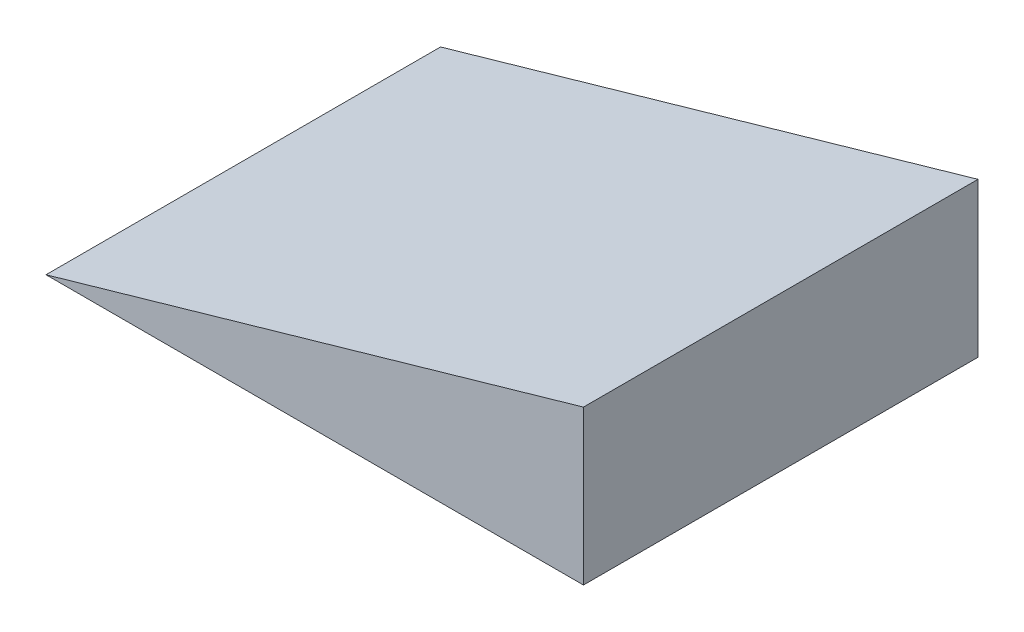
from build123d import *

# Parameters (mm, degrees)
BOSS_EXTRUDE1_DEPTH = 406.4


with BuildPart() as part:
    # Sketch1 → Boss-Extrude1 (new body)
    with BuildSketch(Plane.XY):
        Polygon((0, 0), (0, 158.75), (-553.62704296, 0), align=None)
    extrude(amount=-BOSS_EXTRUDE1_DEPTH)


solid = part.part
